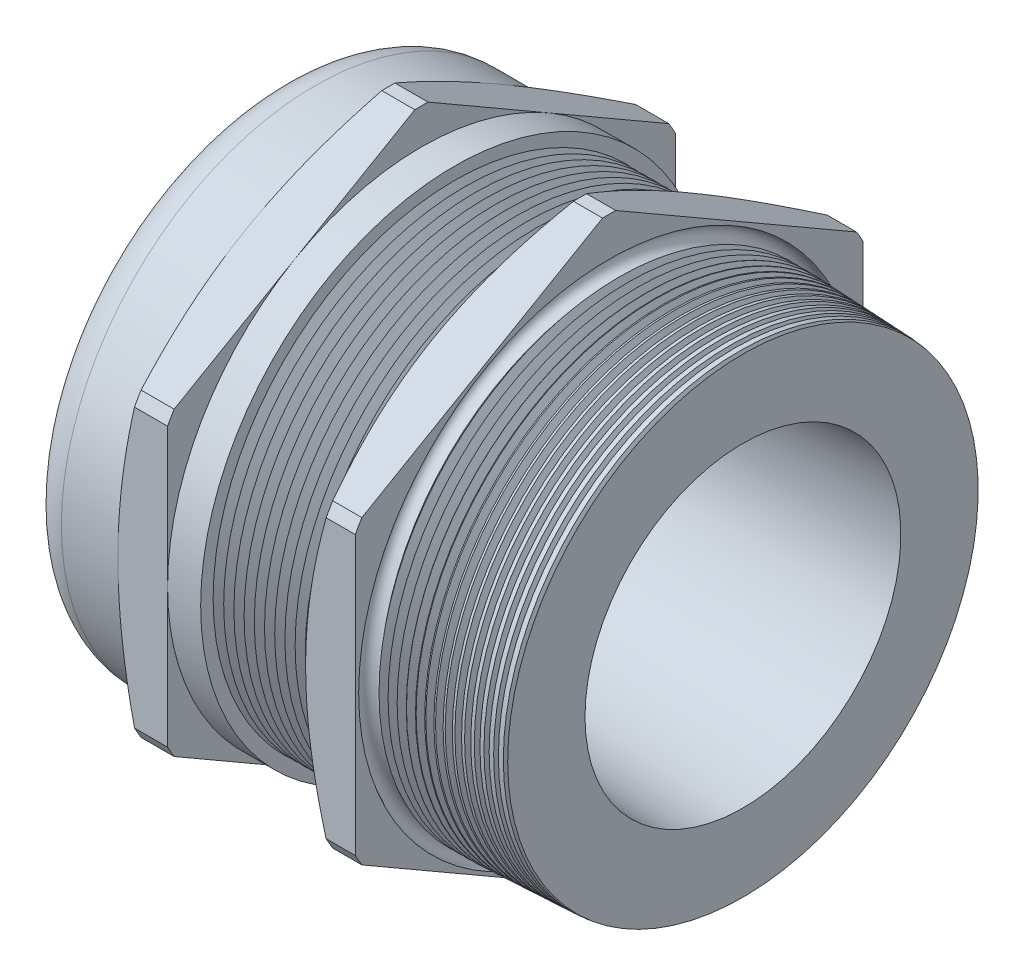
from build123d import *

# Parameters (mm, degrees)
SKETCH6_OUTSIDE_W  = 87.958
SKETCH6_OUTSIDE_H  = 87.958
CUT_EXTRUDE2_DEPTH = 26.5938
SKETCH7_OUTSIDE_W  = 89.944
SKETCH7_OUTSIDE_H  = 97.91
SKETCH7_OUTSIDE_R  = 28.448
CUT_EXTRUDE3_DEPTH = 2.54
CUT_EXTRUDE3_DRAFT = -65
SKETCH9_OUTSIDE_W  = 153.698
SKETCH9_OUTSIDE_H  = 161.664
SKETCH9_OUTSIDE_R  = 28.448
CUT_EXTRUDE5_DEPTH = 21.5486
CUT_EXTRUDE5_DRAFT = -60
LPATTERN1_COUNT    = 10
LPATTERN1_PITCH    = 1.143
LPATTERN2_COUNT    = 15
LPATTERN2_PITCH    = 1.016
FILLET1_R          = 4.153408
SKETCH17_R         = 1.016


with BuildPart() as part:
    # Sketch2 → Revolve1 (revolve)
    with BuildSketch(Plane.XY, mode=Mode.PRIVATE) as revolve1_sk:
        Polygon((-26.035, 21.6408), (-26.035, 28.448), (-15.5448, 28.448), (-15.5448, 32.43072), (-9.9822, 32.43072), (-9.9822, 28.448), (-6.2738, 28.448), (-6.2738, 27.051), (5.4864, 27.051), (5.4864, 32.43072), (11.049, 32.43072), (11.049, 27.051), (26.035, 26.39669711), (26.035, 17.696906322), (-9.9822, 15.494), (-15.5448, 15.494), (-15.5448, 21.6408), align=None)
    revolve(revolve1_sk.sketch.rotate(Axis((-69.075133251, 0, 0), (1, 0, 0)), 90), axis=Axis((-69.075133251, 0, 0), (1, 0, 0)))  # turned: the seam where the file's is

    # Sketch6 outside → Cut-Extrude2 (cut)
    with BuildSketch(Plane(origin=(11.049, 0, 0), x_dir=(0, 0, -1), z_dir=(1, 0, 0))):
        Rectangle(SKETCH6_OUTSIDE_W, SKETCH6_OUTSIDE_H)
        with BuildLine():
            Line((28.448, -15.57122011), (28.448, 15.57122011))
            ThreePointArc((28.448, 15.57122011), (28.085827383, 16.21536), (27.709072183, 16.851080632))
            Line((27.709072183, 16.851080632), (0.738927817, 32.422300742))
            ThreePointArc((0.738927817, 32.422300742), (0, 32.43072), (-0.738927817, 32.422300742))
            Line((-0.738927817, 32.422300742), (-27.709072183, 16.851080632))
            ThreePointArc((-27.709072183, 16.851080632), (-28.085827383, 16.21536), (-28.448, 15.57122011))
            Line((-28.448, 15.57122011), (-28.448, -15.57122011))
            ThreePointArc((-28.448, -15.57122011), (-28.085827383, -16.21536), (-27.709072183, -16.851080632))
            Line((-27.709072183, -16.851080632), (-0.738927817, -32.422300742))
            ThreePointArc((-0.738927817, -32.422300742), (0, -32.43072), (0.738927817, -32.422300742))
            Line((0.738927817, -32.422300742), (27.709072183, -16.851080632))
            ThreePointArc((27.709072183, -16.851080632), (28.085827383, -16.21536), (28.448, -15.57122011))
        make_face(mode=Mode.SUBTRACT)
    extrude(amount=-CUT_EXTRUDE2_DEPTH, mode=Mode.SUBTRACT)


with BuildPart() as cut_extrude3_tool:
    # Sketch7 outside → Cut-Extrude3 (with draft: the straight prism first)
    with BuildSketch(Plane.ZY.offset(15.5448)):
        Rectangle(SKETCH7_OUTSIDE_W, SKETCH7_OUTSIDE_H)
        Circle(SKETCH7_OUTSIDE_R, mode=Mode.SUBTRACT)
    extrude(amount=-CUT_EXTRUDE3_DEPTH)
    # Cut-Extrude3: the draft: its side faces are tilted about the plane it starts from
    cut_extrude3_sides = [cut_extrude3_tool.faces().sort_by_distance(p)[0] for p in [
        (-14.2748, -48.955, 0),
        (-14.2748, 0, 44.972),
        (-14.2748, 48.955, 0),
        (-14.2748, 0, -44.972),
        (-14.2748, 0, -28.448),
    ]]
    draft(cut_extrude3_sides, Plane.ZY.offset(15.5448), CUT_EXTRUDE3_DRAFT)


with BuildPart() as part_1:
    add(part.part)

    # Cut-Extrude3: cut by cut_extrude3_tool
    add(cut_extrude3_tool.part, mode=Mode.SUBTRACT)


with BuildPart() as cut_extrude5_tool:
    # Sketch9 outside → Cut-Extrude5 (with draft: the straight prism first)
    with BuildSketch(Plane.ZY.offset(-5.4864)):
        Rectangle(SKETCH9_OUTSIDE_W, SKETCH9_OUTSIDE_H)
        Circle(SKETCH9_OUTSIDE_R, mode=Mode.SUBTRACT)
    extrude(amount=-CUT_EXTRUDE5_DEPTH)
    # Cut-Extrude5: the draft: its side faces are tilted about the plane it starts from
    cut_extrude5_sides = [cut_extrude5_tool.faces().sort_by_distance(p)[0] for p in [
        (16.2607, -80.832, 0),
        (16.2607, 0, 76.849),
        (16.2607, 80.832, 0),
        (16.2607, 0, -76.849),
        (16.2607, 0, -28.448),
    ]]
    draft(cut_extrude5_sides, Plane.ZY.offset(-5.4864), CUT_EXTRUDE5_DRAFT)


with BuildPart() as part_2:
    add(part_1.part)

    # Cut-Extrude5: cut by cut_extrude5_tool
    add(cut_extrude5_tool.part, mode=Mode.SUBTRACT)

    # Sketch14 → Cut-Revolve1 (revolve, cut)
    with BuildSketch(Plane.XY, mode=Mode.PRIVATE) as cut_revolve1_sk:
        Polygon((-6.2738, 27.051), (-5.100624253, 27.051), (-5.687212127, 26.035), align=None)
    cut_revolve1 = revolve(cut_revolve1_sk.sketch.rotate(Axis((0, 0, 0), (-1, 0, 0)), 270), axis=Axis((0, 0, 0), (-1, 0, 0)), mode=Mode.SUBTRACT)  # turned: the seam where the file's is

    # LPattern1: Cut-Revolve1 ×10
    with Locations(*[(i * LPATTERN1_PITCH, 0, 0) for i in range(1, LPATTERN1_COUNT)]):
        add(cut_revolve1, mode=Mode.SUBTRACT)

    # Sketch15 → Cut-Revolve2 (revolve, cut)
    with BuildSketch(Plane.XY, mode=Mode.PRIVATE) as cut_revolve2_sk:
        Polygon((11.049, 27.051), (12.221059144, 26.999826793), (11.590712274, 26.010380403), align=None)
    cut_revolve2 = revolve(cut_revolve2_sk.sketch.rotate(Axis((0, 0, 0), (1, 0, 0)), 270), axis=Axis((0, 0, 0), (1, 0, 0)), mode=Mode.SUBTRACT)  # turned: the seam where the file's is

    # LPattern2: Cut-Revolve2 ×15
    with Locations(*[(i * LPATTERN2_PITCH, 0, 0) for i in range(1, LPATTERN2_COUNT)]):
        add(cut_revolve2, mode=Mode.SUBTRACT)

    # Fillet1
    fillet1_edges = [part_2.edges().sort_by_distance(p)[0] for p in [
        (-26.035, 0, -28.448),
    ]]
    fillet(fillet1_edges, radius=FILLET1_R)

    # Sketch17 → Cut-Revolve3 (revolve, cut)
    with BuildSketch(Plane.XY, mode=Mode.PRIVATE) as cut_revolve3_sk:
        with Locations((11.0744, -27.051)):
            Circle(SKETCH17_R)
    revolve(cut_revolve3_sk.sketch.rotate(Axis((-69.075133251, 0, 0), (1, 0, 0)), 270), axis=Axis((-69.075133251, 0, 0), (1, 0, 0)), mode=Mode.SUBTRACT)  # turned: the seam where the file's is


with BuildPart() as body_2:
    # Sketch16 → Revolve4 (revolve)
    with BuildSketch(Plane.XY, mode=Mode.PRIVATE) as revolve4_sk:
        with BuildLine():
            Line((-25.019, 21.6408), (-15.5448, 21.6408))
            Line((-15.5448, 21.6408), (-15.5448, 15.494))
            Line((-15.5448, 15.494), (-25.273, 15.494))
            Line((-25.273, 15.494), (-25.273, 21.3868))
            ThreePointArc((-25.273, 21.3868), (-25.198605122, 21.566405122), (-25.019, 21.6408))
        make_face()
    revolve(revolve4_sk.sketch.rotate(Axis((-69.075133251, 0, 0), (1, 0, 0)), 90), axis=Axis((-69.075133251, 0, 0), (1, 0, 0)))  # turned: the seam where the file's is


solid = Compound([part_2.part, body_2.part])
